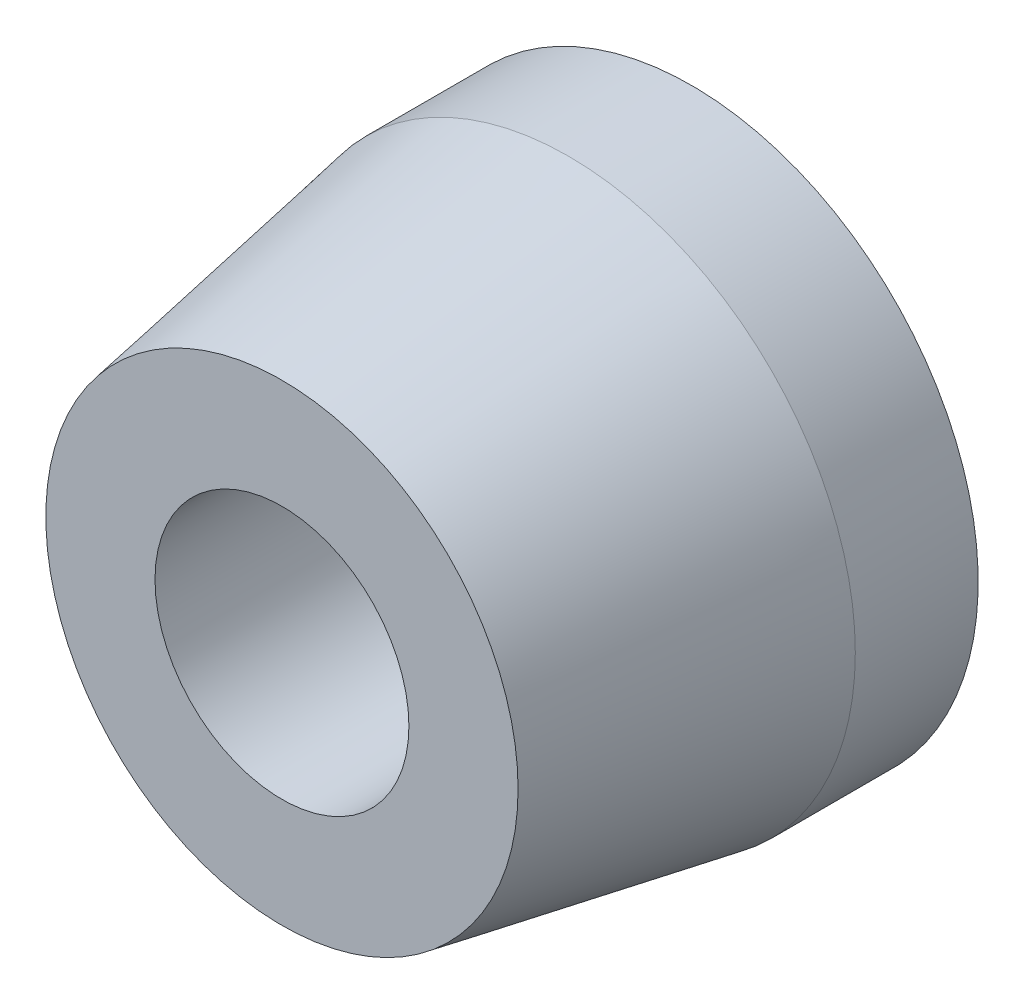
from build123d import *

# Parameters (mm, degrees)
SKETCH1_R           = 7
BOSS_EXTRUDE1_DEPTH = 7
BOSS_EXTRUDE1_TAPER = 10
SKETCH2_R           = 3.1
CUT_EXTRUDE1_DEPTH  = 7
SKETCH3_R           = 7
SKETCH3_R_2         = 1.65
BOSS_EXTRUDE2_DEPTH = 3
SKETCH4_R           = 2.5
SKETCH4_R_2         = 1.65
BOSS_EXTRUDE3_DEPTH = 1.8


with BuildPart() as part:
    # Sketch1 → Boss-Extrude1 (new body)
    with BuildSketch(Plane.XY):
        Circle(SKETCH1_R)
    extrude(amount=BOSS_EXTRUDE1_DEPTH, taper=BOSS_EXTRUDE1_TAPER)

    # Sketch2 → Cut-Extrude1 (cut)
    with BuildSketch(Plane.XY.offset(7)):
        Circle(SKETCH2_R)
    extrude(amount=-CUT_EXTRUDE1_DEPTH, mode=Mode.SUBTRACT)

    # Sketch3 → Boss-Extrude2 (add)
    with BuildSketch(Plane(origin=(0, 0, 0), x_dir=(-1, 0, 0), z_dir=(0, 0, -1))):
        Circle(SKETCH3_R)
        Circle(SKETCH3_R_2, mode=Mode.SUBTRACT)
    extrude(amount=BOSS_EXTRUDE2_DEPTH)

    # Sketch4 → Boss-Extrude3 (add)
    with BuildSketch(Plane(origin=(0, 0, -3), x_dir=(-1, 0, 0), z_dir=(0, 0, -1))):
        Circle(SKETCH4_R)
        Circle(SKETCH4_R_2, mode=Mode.SUBTRACT)
    extrude(amount=BOSS_EXTRUDE3_DEPTH)


solid = part.part
